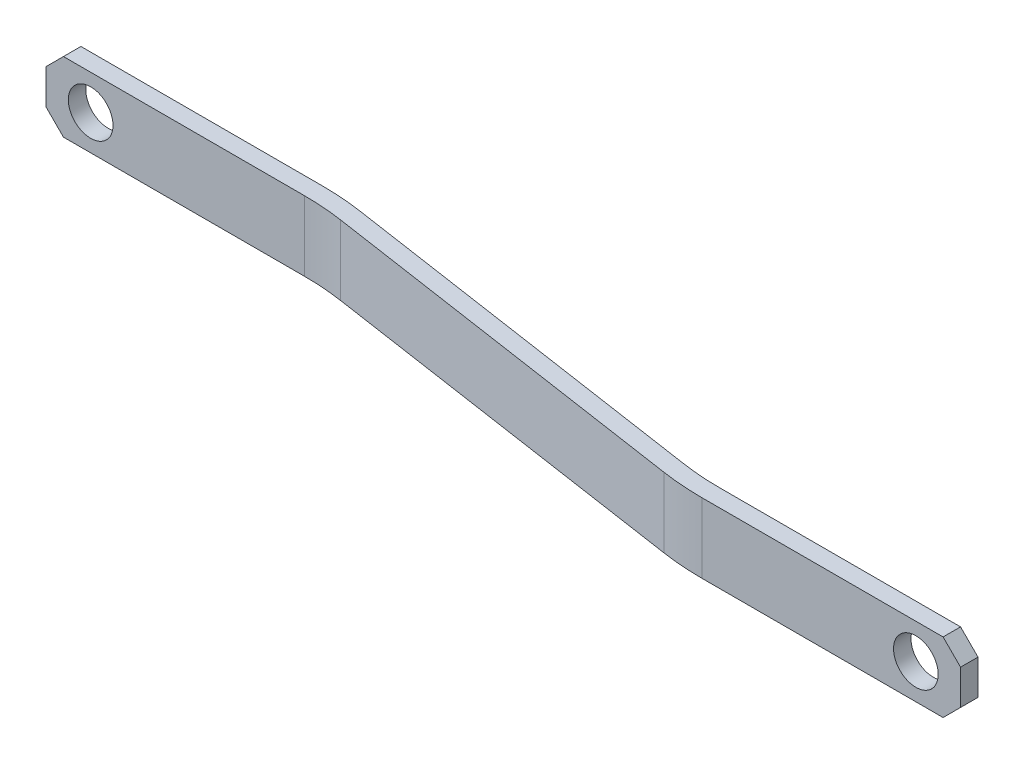
from build123d import *

# Parameters (mm, degrees)
SKETCH1_W          = 177.8
SKETCH1_H          = 12.7
BASE_EXTRUDE_DEPTH = 14.605
EXTRUDE1_DEPTH     = 50.8
SKETCH2_R          = 4.064
CUT_EXTRUDE1_DEPTH = 4.175
SKETCH3_R          = 4.064
CUT_EXTRUDE2_DEPTH = 4.175
CHAMFER1_SIZE      = 3.175
CHAMFER2_SIZE      = 3.175


with BuildPart() as part:
    # Sketch1 → Base-Extrude (new body)
    with BuildSketch(Plane.XY):
        with Locations((88.9, 6.35)):
            Rectangle(SKETCH1_W, SKETCH1_H)
    extrude(amount=BASE_EXTRUDE_DEPTH)


with BuildPart() as body_2:
    # Sketch5 → Extrude1 (new body)
    with BuildSketch(Plane(origin=(0, 12.7, 0), x_dir=(-1, 0, 0), z_dir=(0, 1, 0))):
        with BuildLine():
            Line((0, 0), (-47.022766551, 0))
            ThreePointArc((-47.022766551, 0), (-50.789601569, 0.139848461), (-54.535696978, 0.55862386))
            Line((-54.535696978, 0.55862386), (-123.733861174, 10.906290131))
            ThreePointArc((-123.733861174, 10.906290131), (-127.245825619, 11.298892068), (-130.777233449, 11.43))
            Line((-130.777233449, 11.43), (-177.8, 11.43))
            Line((-177.8, 11.43), (-177.8, 14.605))
            Line((-177.8, 14.605), (-130.777233449, 14.605))
            ThreePointArc((-130.777233449, 14.605), (-127.010398431, 14.465151539), (-123.264303022, 14.04637614))
            Line((-123.264303022, 14.04637614), (-54.066138826, 3.698709869))
            ThreePointArc((-54.066138826, 3.698709869), (-50.554174381, 3.306107932), (-47.022766551, 3.175))
            Line((-47.022766551, 3.175), (0, 3.175))
            Line((0, 3.175), (0, 0))
        make_face()
    extrude(amount=-EXTRUDE1_DEPTH)


with BuildPart() as part_1:
    add(part.part)

    # Combine1: intersect body 2
    add(body_2.part, mode=Mode.INTERSECT)

    # Sketch2 → Cut-Extrude1 (cut, through all)
    with BuildSketch(Plane.XY.offset(3.175)):
        with Locations((8.128, 6.35)):
            Circle(SKETCH2_R)
    extrude(amount=-CUT_EXTRUDE1_DEPTH, mode=Mode.SUBTRACT)

    # Sketch3 → Cut-Extrude2 (cut, through all)
    with BuildSketch(Plane(origin=(185.269572221, -0.228654981, 11.43), x_dir=(1, 0, 0), z_dir=(0, 0, 1))):
        with Locations((-15.597572221, 6.578654981)):
            Circle(SKETCH3_R)
    extrude(amount=CUT_EXTRUDE2_DEPTH, mode=Mode.SUBTRACT)

    # Chamfer1
    chamfer1_edges = [part_1.edges().sort_by_distance(p)[0] for p in [
        (177.8, 0, 13.0175),
        (177.8, 12.7, 13.0175),
    ]]
    chamfer(chamfer1_edges, length=CHAMFER1_SIZE)

    # Chamfer2
    chamfer2_edges = [part_1.edges().sort_by_distance(p)[0] for p in [
        (0, 12.7, 1.5875),
        (0, 0, 1.5875),
    ]]
    chamfer(chamfer2_edges, length=CHAMFER2_SIZE)


solid = part_1.part
